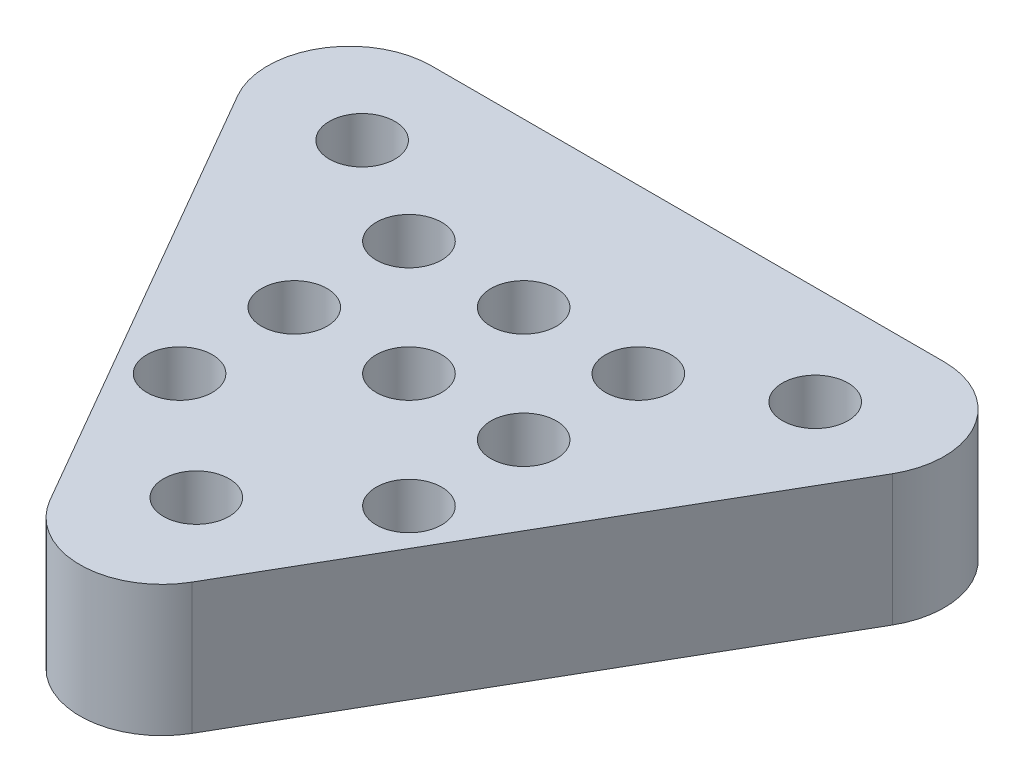
from build123d import *

# Parameters (mm, degrees)
SKETCH1_R      = 1
EXTRUDE1_DEPTH = 4
SKETCH1_3_R    = 2.38125
EXTRUDE4_DEPTH = 2


with BuildPart() as part:
    # Sketch1 → Extrude1 (new body)
    with BuildSketch(Plane(origin=(0, 0, 0), x_dir=(1, 0, 0), z_dir=(0, 1, 0))):
        with BuildLine():
            Line((-5.186041147, 3.316192399), (2.637731834, -10.234979911))
            ThreePointArc((2.637731834, -10.234979911), (4.802795343, -11.484979911), (6.967858853, -10.234979911))
            Line((6.967858853, -10.234979911), (14.791631834, 3.316192399))
            ThreePointArc((14.791631834, 3.316192399), (14.791631834, 5.816192399), (12.626568324, 7.066192399))
            Line((12.626568324, 7.066192399), (-3.020977638, 7.066192399))
            ThreePointArc((-3.020977638, 7.066192399), (-5.186041147, 5.816192399), (-5.186041147, 3.316192399))
        make_face()
        with Locations((-2.110635714, 4.040606244)):
            Circle(SKETCH1_R, mode=Mode.SUBTRACT)
        with Locations((11.7162264, 4.040606244)):
            Circle(SKETCH1_R, mode=Mode.SUBTRACT)
        with Locations((4.802795343, -7.933807601)):
            Circle(SKETCH1_R, mode=Mode.SUBTRACT)
        with Locations((1.270334632, 2.088602105)):
            Circle(SKETCH1_R, mode=Mode.SUBTRACT)
        with Locations((4.770334632, 2.088602105)):
            Circle(SKETCH1_R, mode=Mode.SUBTRACT)
        with Locations((8.270334632, 2.088602105)):
            Circle(SKETCH1_R, mode=Mode.SUBTRACT)
        with Locations((1.270334632, -1.411397895)):
            Circle(SKETCH1_R, mode=Mode.SUBTRACT)
        with Locations((4.770334632, -1.411397895)):
            Circle(SKETCH1_R, mode=Mode.SUBTRACT)
        with Locations((8.270334632, -1.411397895)):
            Circle(SKETCH1_R, mode=Mode.SUBTRACT)
        with Locations((1.270334632, -4.911397895)):
            Circle(SKETCH1_R, mode=Mode.SUBTRACT)
        with Locations((8.270334632, -4.911397895)):
            Circle(SKETCH1_R, mode=Mode.SUBTRACT)
    extrude(amount=EXTRUDE1_DEPTH)

    # Sketch1_3 → Extrude4 (cut)
    with BuildSketch(Plane(origin=(0, 0, 0), x_dir=(1, 0, 0), z_dir=(0, 1, 0))):
        with Locations((-2.110635714, 4.040606244)):
            Circle(SKETCH1_3_R)
        with Locations((4.802795343, -7.933807601)):
            Circle(SKETCH1_3_R)
        with Locations((11.7162264, 4.040606244)):
            Circle(SKETCH1_3_R)
    extrude(amount=EXTRUDE4_DEPTH, mode=Mode.SUBTRACT)


solid = part.part
